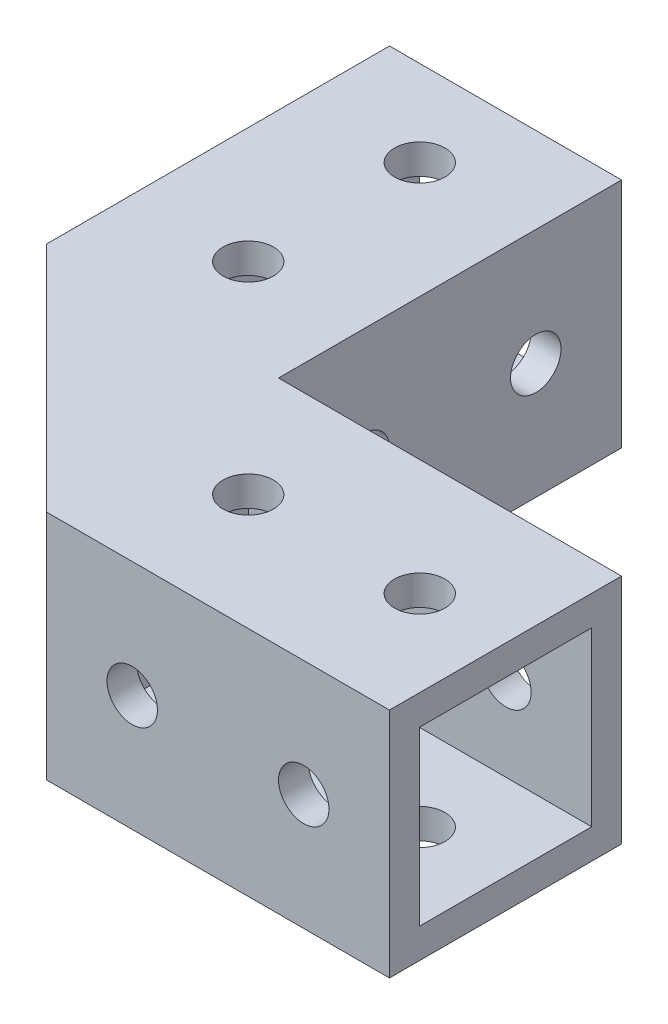
from build123d import *

# Parameters (mm, degrees)
SKETCH1_W           = 34
SKETCH1_H           = 23
SKETCH1_R           = 2.5
BOSS_EXTRUDE1_DEPTH = 23
SKETCH6_OUTSIDE_W   = 45.41
SKETCH6_OUTSIDE_H   = 34.41
SKETCH6_OUTSIDE_W_2 = 34
SKETCH6_OUTSIDE_H_2 = 23
SKETCH6_OUTSIDE_R   = 2.5
CUT_EXTRUDE10_DEPTH = 24
SKETCH7_OUTSIDE_W   = 34.41
SKETCH7_OUTSIDE_H   = 34.41
SKETCH7_OUTSIDE_W_2 = 23
SKETCH7_OUTSIDE_H_2 = 23
SKETCH7_OUTSIDE_W_3 = 17.08
SKETCH7_OUTSIDE_H_3 = 17.08
CUT_EXTRUDE11_DEPTH = 34
BOSS_EXTRUDE2_DEPTH = 23
SKETCH13_R          = 2.5
BOSS_EXTRUDE3_DEPTH = 4


with BuildPart() as part:
    # sketch1 → Boss-Extrude1 (new body)
    with BuildSketch(Plane(origin=(0, 0, 0), x_dir=(1, 0, 0), z_dir=(0, 1, 0))):
        with Locations((17, -11.5)):
            Rectangle(SKETCH1_W, SKETCH1_H)
        with Locations((8.5, -11.5)):
            Circle(SKETCH1_R, mode=Mode.SUBTRACT)
        with Locations((25.5, -11.5)):
            Circle(SKETCH1_R, mode=Mode.SUBTRACT)
    extrude(amount=BOSS_EXTRUDE1_DEPTH)

    # Sketch6 outside → Cut-Extrude10 (cut, through all)
    with BuildSketch(Plane(origin=(0, 0, 0), x_dir=(-1, 0, 0), z_dir=(0, 0, -1))):
        with Locations((-17, 11.5)):
            Rectangle(SKETCH6_OUTSIDE_W, SKETCH6_OUTSIDE_H)
        with Locations((-17, 11.5)):
            Rectangle(SKETCH6_OUTSIDE_W_2, SKETCH6_OUTSIDE_H_2, mode=Mode.SUBTRACT)
        with Locations((-25.5, 11.5)):
            Circle(SKETCH6_OUTSIDE_R)
        with Locations((-8.5, 11.5)):
            Circle(SKETCH6_OUTSIDE_R)
    extrude(amount=-CUT_EXTRUDE10_DEPTH, mode=Mode.SUBTRACT)

    # Sketch7 outside → Cut-Extrude11 (cut)
    with BuildSketch(Plane(origin=(34, 0, 0), x_dir=(0, 0, -1), z_dir=(1, 0, 0))):
        with Locations((-11.5, 11.5)):
            Rectangle(SKETCH7_OUTSIDE_W, SKETCH7_OUTSIDE_H)
        with Locations((-11.5, 11.5)):
            Rectangle(SKETCH7_OUTSIDE_W_2, SKETCH7_OUTSIDE_H_2, mode=Mode.SUBTRACT)
        with Locations((-11.5, 11.5)):
            Rectangle(SKETCH7_OUTSIDE_W_3, SKETCH7_OUTSIDE_H_3)
    extrude(amount=-CUT_EXTRUDE11_DEPTH, mode=Mode.SUBTRACT)


with BuildPart() as body_2:
    # Mirror6: mirrored copy
    add(part.part.mirror(Plane(origin=(0, 0, 0), x_dir=(-0.707106781, 0, 0.707106781), z_dir=(-0.707106781, 0, -0.707106781))))


with BuildPart() as part_1:
    add(part.part)

    add(body_2.part)  # Boss-Extrude2 merges body 2
    # Sketch11 → Boss-Extrude2 (add)
    with BuildSketch(Plane(origin=(0, 0, 0), x_dir=(1, 0, 0), z_dir=(0, 1, 0))):
        Polygon((-23, 0), (0, -23), (0, 0), align=None)
    extrude(amount=BOSS_EXTRUDE2_DEPTH)

    # Sketch13 → Boss-Extrude3 (add)
    with BuildSketch(Plane(origin=(0, 0, 0), x_dir=(1, 0, 0), z_dir=(0, 1, 0))):
        Polygon((8.706365938, 8.706365938), (0, 17), (0, 0), (17, 0), align=None)
        with Locations((5.170832032, 5.170832032)):
            Circle(SKETCH13_R, mode=Mode.SUBTRACT)
    extrude(amount=BOSS_EXTRUDE3_DEPTH)


solid = part_1.part
